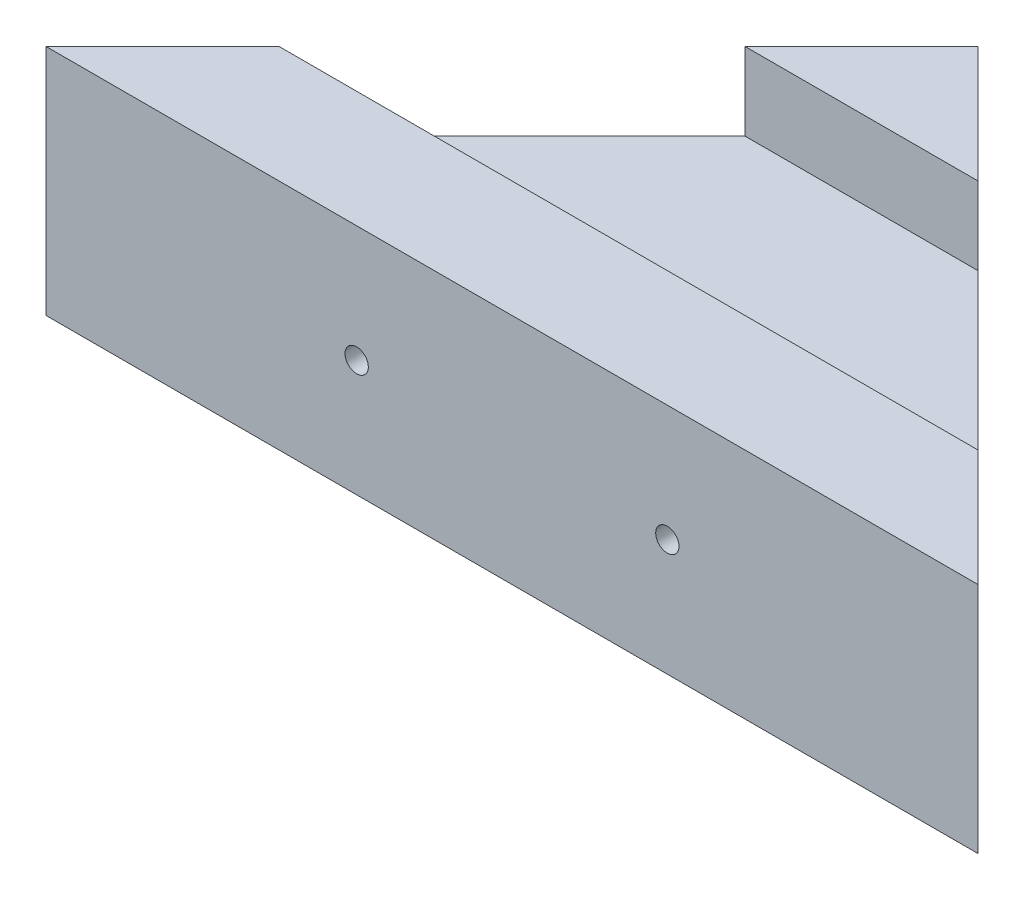
from build123d import *

# Parameters (mm, degrees)
BOSS_EXTRUDE1_DEPTH = 15
CUT_EXTRUDE1_DEPTH  = 5
SKETCH4_R           = 0.75
CUT_EXTRUDE2_DEPTH  = 22.5


with BuildPart() as part:
    # Sketch1 → Boss-Extrude1 (new body)
    with BuildSketch(Plane(origin=(0, 0, 0), x_dir=(1, 0, 0), z_dir=(0, 1, 0))):
        Polygon((0, 0), (60, 0), (30, 30), align=None)
    extrude(amount=BOSS_EXTRUDE1_DEPTH)

    # Sketch3 → Cut-Extrude1 (cut)
    with BuildSketch(Plane(origin=(0, 15, 0), x_dir=(1, 0, 0), z_dir=(0, 1, 0))):
        Polygon((7.5, 7.5), (52.5, 7.5), (37.5, 22.5), (22.5, 22.5), align=None)
    extrude(amount=-CUT_EXTRUDE1_DEPTH, mode=Mode.SUBTRACT)

    # Sketch4 → Cut-Extrude2 (cut)
    with BuildSketch(Plane.XY):
        with Locations((20, 7.5)):
            Circle(SKETCH4_R)
        with Locations((40, 7.5)):
            Circle(SKETCH4_R)
    extrude(amount=-CUT_EXTRUDE2_DEPTH, mode=Mode.SUBTRACT)


solid = part.part
